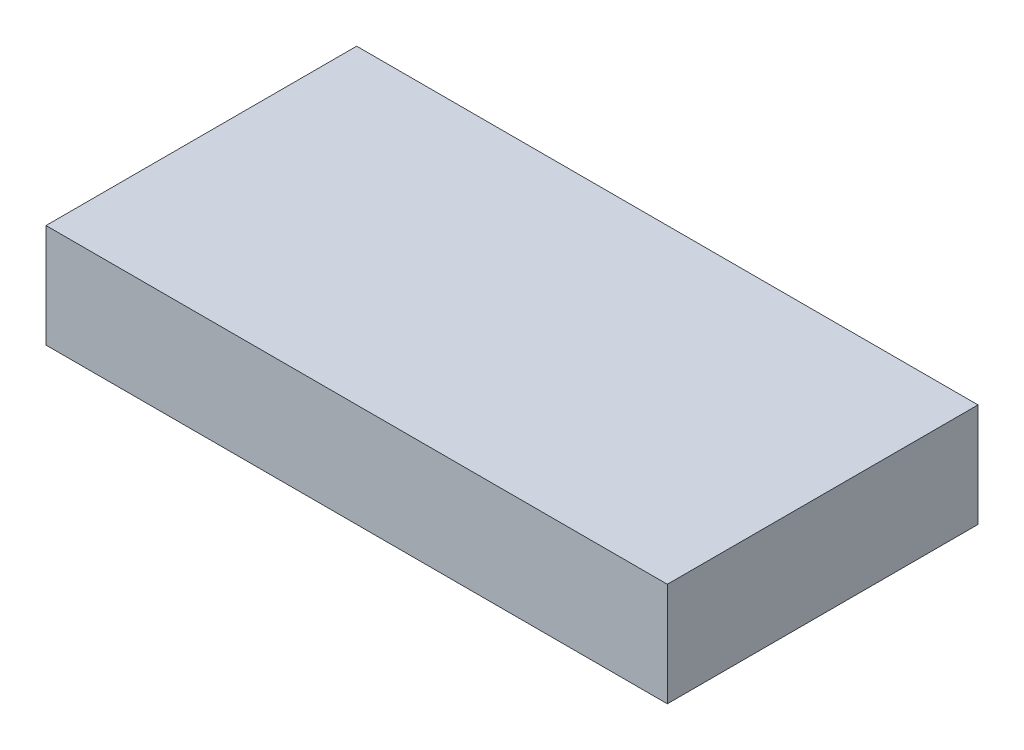
from build123d import *

# Parameters (mm, degrees)
SKETCH1_W           = 60
SKETCH1_H           = 30
BOSS_EXTRUDE1_DEPTH = 10


with BuildPart() as part:
    # Sketch1 → Boss-Extrude1 (new body)
    with BuildSketch(Plane(origin=(0, 0, 0), x_dir=(1, 0, 0), z_dir=(0, 1, 0))):
        with Locations((30, 15)):
            Rectangle(SKETCH1_W, SKETCH1_H)
    extrude(amount=BOSS_EXTRUDE1_DEPTH)


solid = part.part
